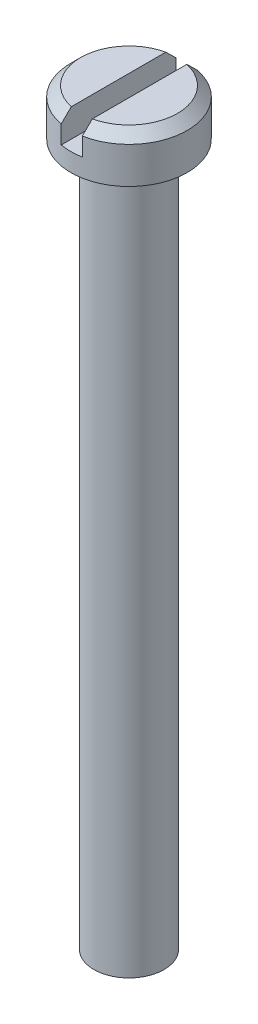
from build123d import *

# Parameters (mm, degrees)
CHAMFER1_SIZE           = 0.7
SKETCH2_W               = 1.5
SKETCH2_H               = 6.7872108
CUT_EXTRUDE1_DEPTH      = 50
CUT_EXTRUDE1_DEPTH_BACK = 19


with BuildPart() as part:
    # Sketch1 → Revolve1 (revolve)
    with BuildSketch(Plane.XY):
        Polygon((0, 53.3), (4.15, 53.3), (4.15, 50), (2.5, 50), (2.5, 0), (0, 0), (0, 50), align=None)
    revolve(axis=Axis((0, 0, 0), (0, 1, 0)))

    # Chamfer1
    chamfer1_edges = [part.edges().sort_by_distance(p)[0] for p in [
        (-4.15, 53.3, 0),
    ]]
    chamfer(chamfer1_edges, length=CHAMFER1_SIZE)

    # Sketch2 → Cut-Extrude1 (cut, two sides)
    with BuildSketch(Plane.XY) as cut_extrude1_sk:
        with Locations((0.003512463, 54.6936054)):
            Rectangle(SKETCH2_W, SKETCH2_H)
    extrude(amount=CUT_EXTRUDE1_DEPTH, mode=Mode.SUBTRACT)
    extrude(cut_extrude1_sk.sketch, amount=-CUT_EXTRUDE1_DEPTH_BACK, mode=Mode.SUBTRACT)


solid = part.part
